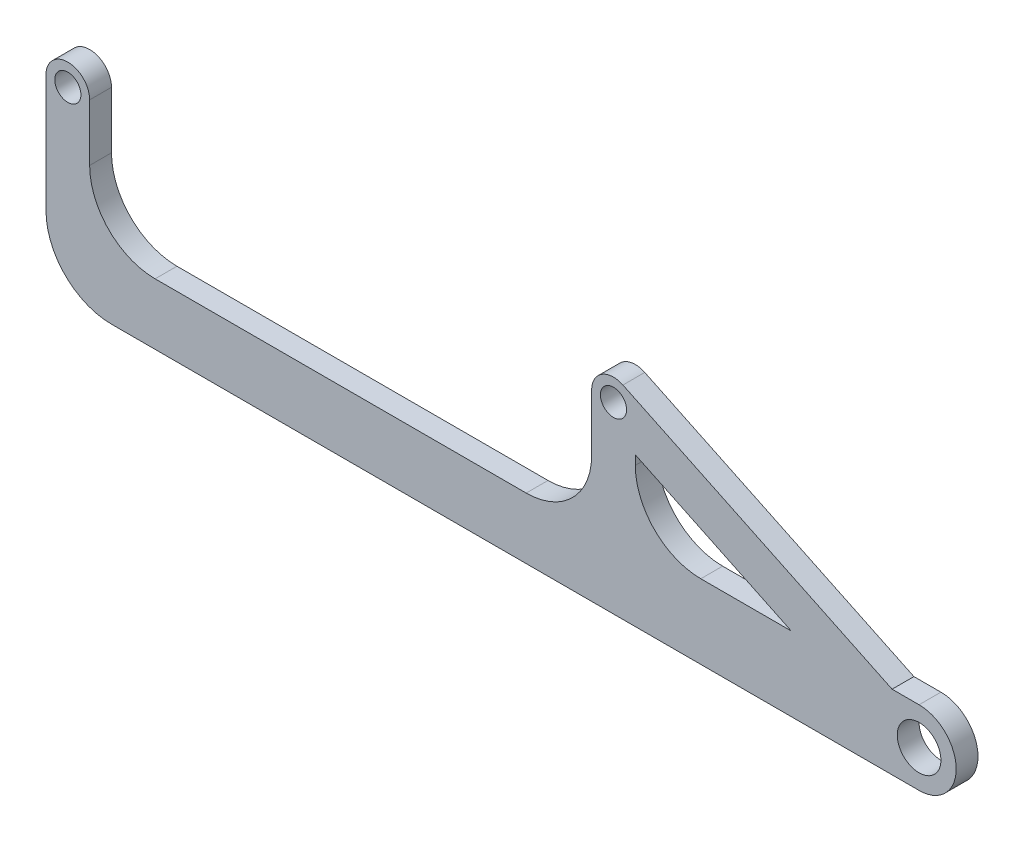
from build123d import *

# Parameters (mm, degrees)
SKETCH1_R           = 3
BOSS_EXTRUDE1_DEPTH = 5


with BuildPart() as part:
    # Sketch1 → Boss-Extrude1 (new body)
    with BuildSketch(Plane.XY):
        with BuildLine():
            ThreePointArc((195, -42), (203.5, -33.5), (195, -25))
            Line((195, -25), (188.821366739, -25))
            Line((188.821366739, -25), (127.15841734, 4.510125784))
            ThreePointArc((127.15841734, 4.510125784), (122.334675132, 4.230371538), (120, 0))
            Line((120, 0), (120, -13))
            ThreePointArc((120, -13), (115.606601718, -23.606601718), (105, -28))
            Line((105, -28), (20, -28))
            ThreePointArc((20, -28), (9.393398282, -23.606601718), (5, -13))
            Line((5, -13), (5, 0))
            ThreePointArc((5, 0), (0, 5), (-5, 0))
            Line((-5, 0), (-5, -27))
            ThreePointArc((-5, -27), (-0.606601734, -37.606601701), (9.999999954, -42))
            Line((9.999999954, -42), (195, -42))
        make_face()
        with BuildLine():
            Line((196.651752124, -28.780708218), (196.661737841, -28.752177599))
            Line((196.661737841, -28.752177599), (197.15841734, -28.989874216))
            ThreePointArc((197.15841734, -28.989874216), (193.092046793, -38.121657123), (196.651752124, -28.780708218))
        make_face(mode=Mode.SUBTRACT)
        with BuildLine():
            Line((130, -7.902630298), (165.725847138, -25))
            Line((165.725847138, -25), (145, -25))
            ThreePointArc((145, -25), (134.393398282, -20.606601718), (130, -10))
            Line((130, -10), (130, -7.902630298))
        make_face(mode=Mode.SUBTRACT)
        with Locations((125, 0)):
            Circle(SKETCH1_R, mode=Mode.SUBTRACT)
        Circle(SKETCH1_R, mode=Mode.SUBTRACT)
    extrude(amount=BOSS_EXTRUDE1_DEPTH)


solid = part.part
